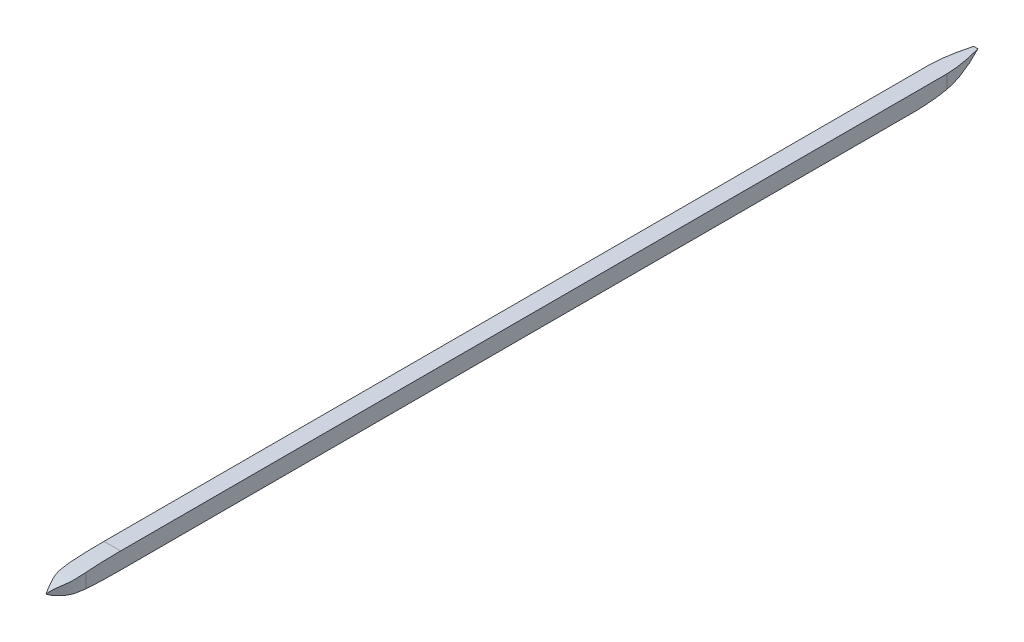
from build123d import *

# Parameters (mm, degrees)
SKETCH2_W           = 711.2
SKETCH2_H           = 12.7
BOSS_EXTRUDE2_DEPTH = 6.35
CUT_EXTRUDE1_DEPTH  = 13.7
CUT_EXTRUDE2_DEPTH  = 13.7000001
CUT_EXTRUDE3_DEPTH  = 13.7000001
CUT_EXTRUDE4_DEPTH  = 13.7000001


with BuildPart() as part:
    # Sketch2 → Boss-Extrude2 (new body, symmetric)
    with BuildSketch(Plane(origin=(0, 0, 0), x_dir=(0, 0, -1), z_dir=(1, 0, 0))):
        Rectangle(SKETCH2_W, SKETCH2_H)
    extrude(amount=BOSS_EXTRUDE2_DEPTH, both=True)

    # Sketch4 → Cut-Extrude1 (cut, through all)
    with BuildSketch(Plane(origin=(6.35, 0, 0), x_dir=(0, 0, -1), z_dir=(1, 0, 0))):
        with BuildLine():
            Line((-304.87408605, 6.35), (-304.87408605, 13.865538478))
            Line((-304.87408605, 13.865538478), (-363.512264419, 13.865538478))
            Line((-363.512264419, 13.865538478), (-363.512264419, -12.328277535))
            Line((-363.512264419, -12.328277535), (-304.874567486, -12.328277535))
            Line((-304.874567486, -12.328277535), (-304.874567486, -6.35))
            add(Edge.make_bspline(
                [(-355.6, 0), (-348.097307304, -6.35), (-304.874567486, -6.35)],
                knots=[0, 0, 0, 1, 1, 1], degree=2))
            add(Edge.make_bspline(
                [(-355.6, 0), (-345.591229217, 6.35), (-304.87408605, 6.35)],
                knots=[0, 0, 0, 1, 1, 1], degree=2))
        make_face()
    extrude(amount=-CUT_EXTRUDE1_DEPTH, mode=Mode.SUBTRACT)

    # Sketch5 → Cut-Extrude2 (cut, through all)
    with BuildSketch(Plane(origin=(0, 6.35, 0), x_dir=(1, 0, 0), z_dir=(0, 1, 0))):
        with BuildLine():
            Line((-6.35, -304.87408605), (-23.988893808, -304.87408605))
            Line((-23.988893808, -304.87408605), (-23.988893808, -362.653977565))
            Line((-23.988893808, -362.653977565), (16.903963191, -362.653977565))
            Line((16.903963191, -362.653977565), (16.903963191, -304.87408605))
            Line((16.903963191, -304.87408605), (6.35, -304.87408605))
            add(Edge.make_bspline(
                [(6.35, -304.87408605), (6.35, -345.744640536), (7.326296323, -338.596228196), (0, -355.6)],
                knots=[0, 0, 0, 0, 1, 1, 1, 1], degree=3))
            add(Edge.make_bspline(
                [(-6.35, -304.87408605), (-6.35, -345.744640536), (-7.326296323, -338.596228196), (0, -355.6)],
                knots=[0, 0, 0, 0, 1, 1, 1, 1], degree=3))
        make_face()
    extrude(amount=-CUT_EXTRUDE2_DEPTH, mode=Mode.SUBTRACT)

    # Sketch6 → Cut-Extrude3 (cut, through all)
    with BuildSketch(Plane(origin=(6.35, 0, 0), x_dir=(0, 0, -1), z_dir=(1, 0, 0))):
        with BuildLine():
            Line((286.848717456, -6.35), (286.848717456, -20.474403892))
            Line((286.848717456, -20.474403892), (367.422975775, -20.474403892))
            Line((367.422975775, -20.474403892), (367.422975775, 6.35))
            Line((367.422975775, 6.35), (355.6, 6.35))
            add(Edge.make_bspline(
                [(355.6, 6.35), (329.990285951, -6.563724339), (313.323760361, -6.629041346), (286.848717456, -6.35)],
                knots=[0, 0, 0, 0, 1, 1, 1, 1], degree=3))
        make_face()
    extrude(amount=-CUT_EXTRUDE3_DEPTH, mode=Mode.SUBTRACT)

    # Sketch7 → Cut-Extrude4 (cut, through all)
    with BuildSketch(Plane(origin=(0, 6.35, 0), x_dir=(1, 0, 0), z_dir=(0, 1, 0))):
        with BuildLine():
            Line((1.651, 355.6), (-1.651, 355.6))
            add(Edge.make_bspline(
                [(-1.651, 355.6), (-7.543065091, 333.607768993), (-6.35, 324.690959151), (-6.35, 310.113688271)],
                knots=[0, 0, 0, 0, 1, 1, 1, 1], degree=3))
            Line((-6.35, 310.113688271), (-23.620546209, 310.113688271))
            Line((-23.620546209, 310.113688271), (-23.620546209, 363.551883896))
            Line((-23.620546209, 363.551883896), (18.925820136, 363.551883896))
            Line((18.925820136, 363.551883896), (18.925820136, 310.113688271))
            Line((18.925820136, 310.113688271), (6.35, 310.113688271))
            add(Edge.make_bspline(
                [(1.651, 355.6), (7.543065091, 333.607768993), (6.35, 324.690959151), (6.35, 310.113688271)],
                knots=[0, 0, 0, 0, 1, 1, 1, 1], degree=3))
        make_face()
    extrude(amount=-CUT_EXTRUDE4_DEPTH, mode=Mode.SUBTRACT)


solid = part.part
